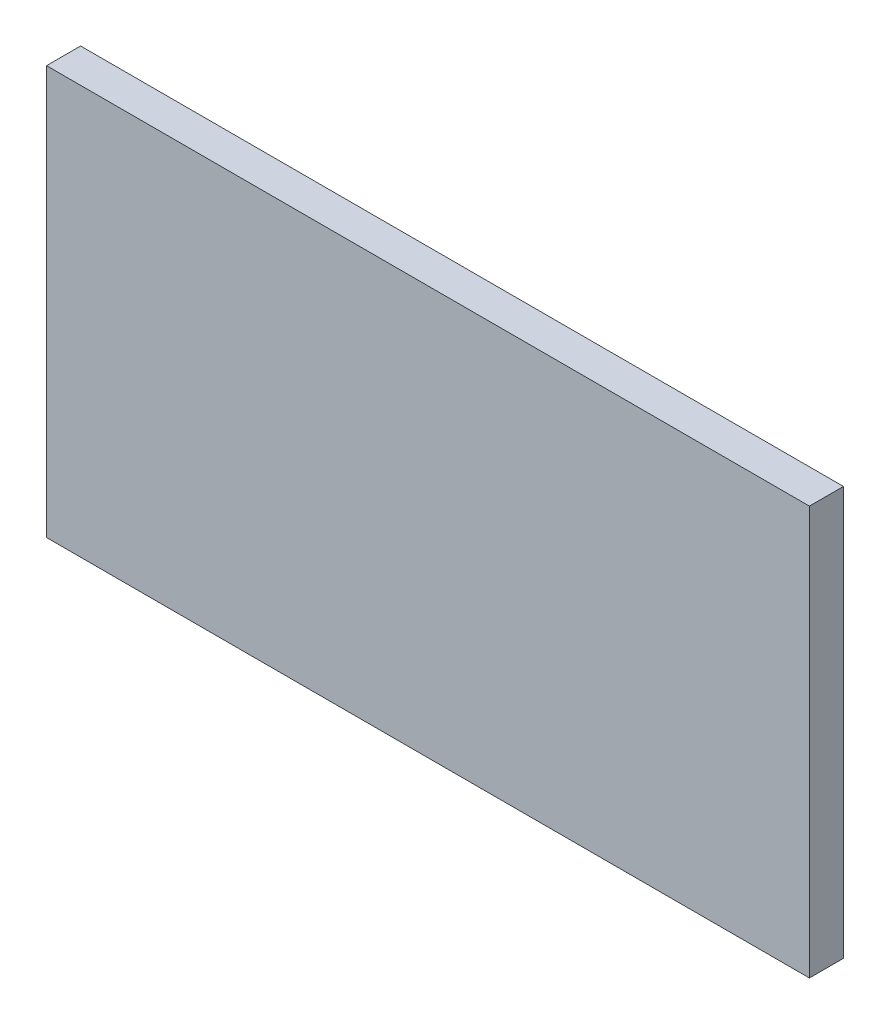
from build123d import *

# Parameters (mm, degrees)
SKETCH1_W           = 71.12
SKETCH1_H           = 38.1
BOSS_EXTRUDE1_DEPTH = 3.175


with BuildPart() as part:
    # Sketch1 → Boss-Extrude1 (new body)
    with BuildSketch(Plane.XY):
        with Locations((35.56, 19.05)):
            Rectangle(SKETCH1_W, SKETCH1_H)
    extrude(amount=BOSS_EXTRUDE1_DEPTH)


solid = part.part
